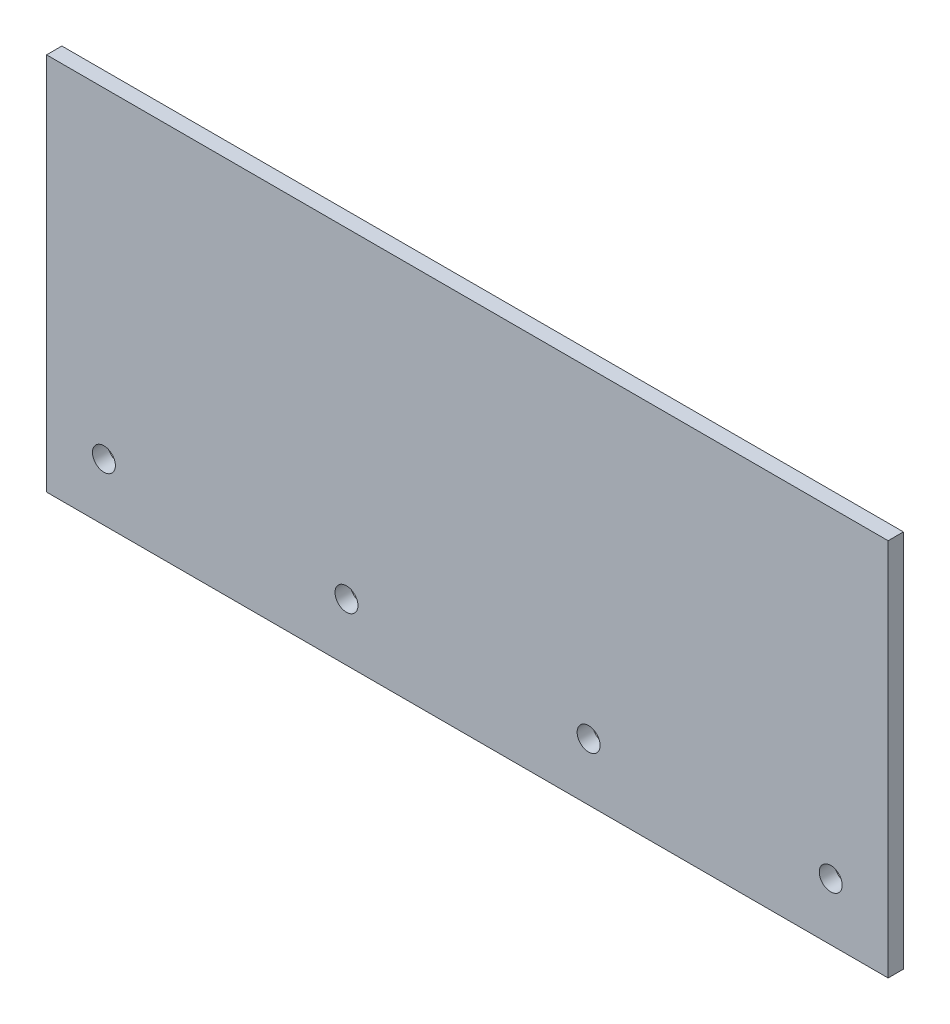
from build123d import *

# Parameters (mm, degrees)
SKICA1_W                = 220
SKICA1_H                = 99
SKICA1_R                = 3
P_IDAT_VYSUNUT_M1_DEPTH = 4


with BuildPart() as part:
    # Skica1 → Přidat vysunutím1 (new body)
    with BuildSketch(Plane.XY):
        with Locations((110, 49.5)):
            Rectangle(SKICA1_W, SKICA1_H)
        with Locations((205, 15)):
            Circle(SKICA1_R, mode=Mode.SUBTRACT)
        with Locations((15, 15)):
            Circle(SKICA1_R, mode=Mode.SUBTRACT)
        with Locations((141.7, 15)):
            Circle(SKICA1_R, mode=Mode.SUBTRACT)
        with Locations((78.4, 15)):
            Circle(SKICA1_R, mode=Mode.SUBTRACT)
    extrude(amount=P_IDAT_VYSUNUT_M1_DEPTH)


solid = part.part
